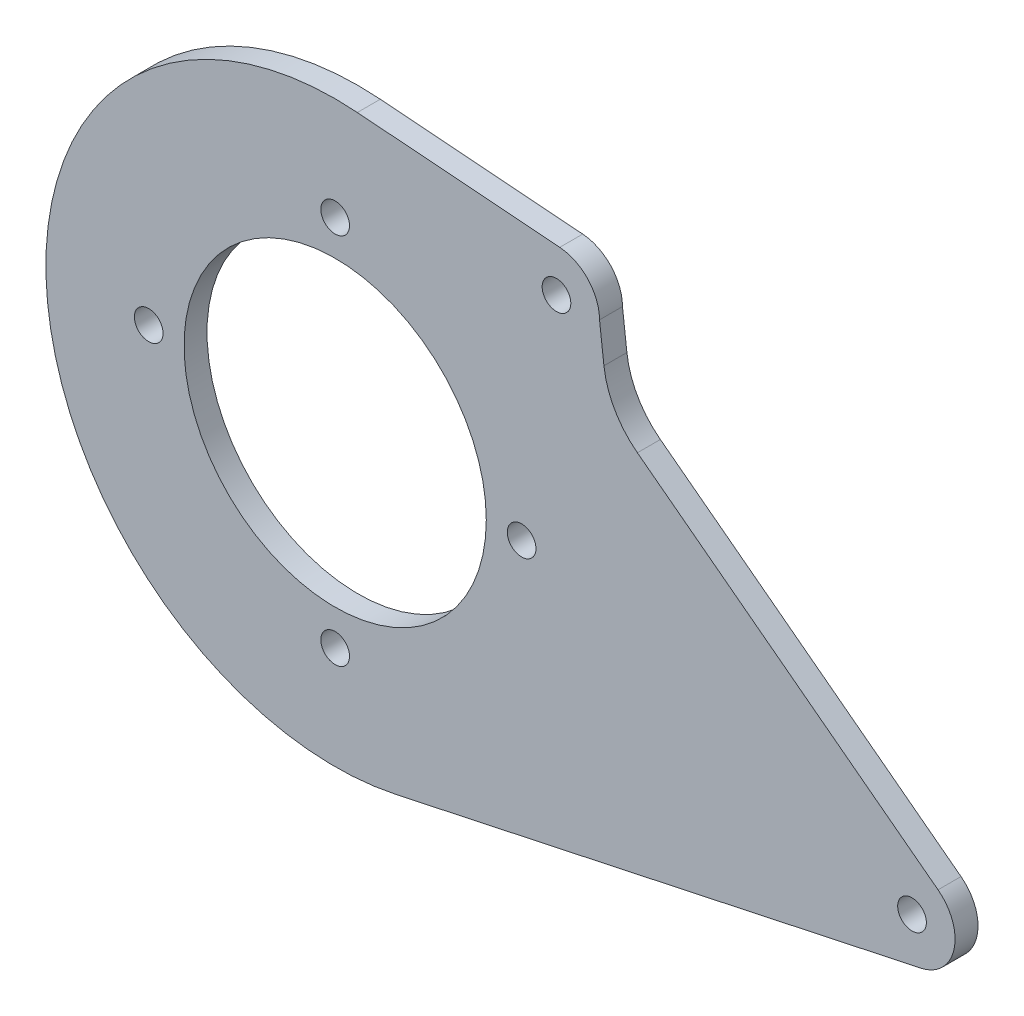
from build123d import *

# Parameters (mm, degrees)
SKETCH2_R           = 66.87
SKETCH2_R_2         = 6.35
BOSS_EXTRUDE1_DEPTH = 10.16


with BuildPart() as part:
    # Sketch2 → Boss-Extrude1 (new body)
    with BuildSketch(Plane.XY):
        with BuildLine():
            Line((26.712768377, -125.181580137), (259.206689864, -75.569198931))
            ThreePointArc((259.206689864, -75.569198931), (273.828874964, -61.087881293), (266.753249652, -41.762965146))
            Line((266.753249652, -41.762965146), (133.724592453, 59.199527533))
            ThreePointArc((133.724592453, 59.199527533), (123.675557689, 70.65008379), (118.916102857, 85.122330608))
            Line((118.916102857, 85.122330608), (116.971447392, 101.747964629))
            ThreePointArc((116.971447392, 101.747964629), (111.898242951, 114.692140381), (99.380719213, 120.741990683))
            Line((99.380719213, 120.741990683), (9.805081003, 127.623902097))
            ThreePointArc((9.805081003, 127.623902097), (-127.714687068, -8.541586927), (26.712768377, -125.181580137))
        make_face()
        Circle(SKETCH2_R, mode=Mode.SUBTRACT)
        with Locations((0, 82.5)):
            Circle(SKETCH2_R_2, mode=Mode.SUBTRACT)
        with Locations((-82.5, 0)):
            Circle(SKETCH2_R_2, mode=Mode.SUBTRACT)
        with Locations((0, -82.5)):
            Circle(SKETCH2_R_2, mode=Mode.SUBTRACT)
        with Locations((82.5, 0)):
            Circle(SKETCH2_R_2, mode=Mode.SUBTRACT)
        with Locations((255.236487197, -56.93750575)):
            Circle(SKETCH2_R_2, mode=Mode.SUBTRACT)
        with Locations((97.921447392, 101.747964629)):
            Circle(SKETCH2_R_2, mode=Mode.SUBTRACT)
    extrude(amount=BOSS_EXTRUDE1_DEPTH)


solid = part.part
